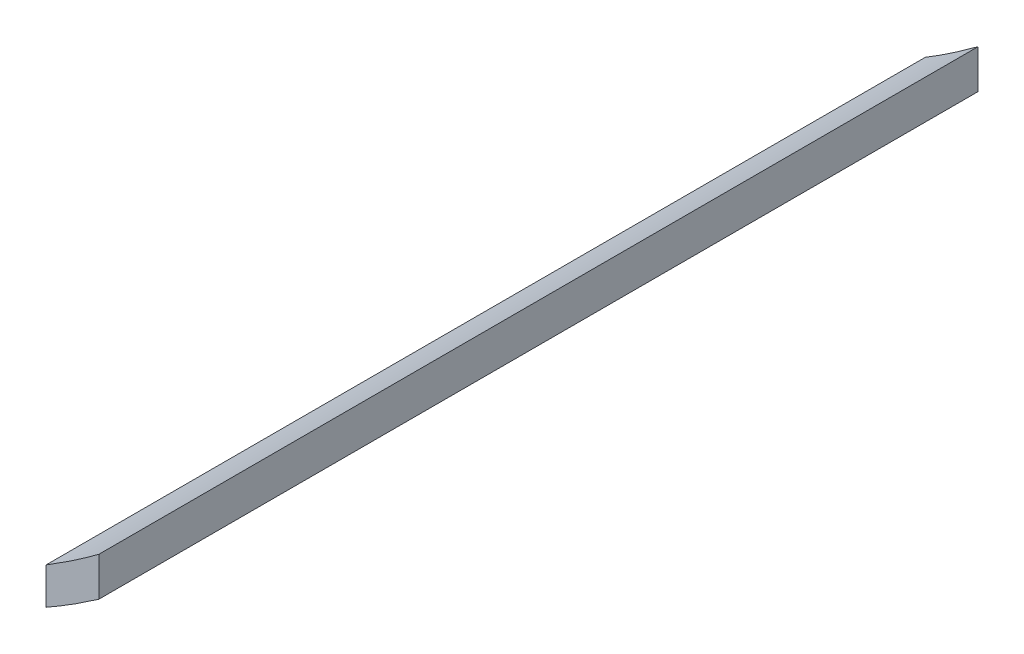
from build123d import *

# Parameters (mm, degrees)
BOSS_EXTRUDE1_DEPTH = 50


with BuildPart() as part:
    # Sketch1 → Boss-Extrude1 (new body)
    with BuildSketch(Plane.XY):
        with BuildLine():
            Line((124.702606635, -48.542565188), (124.702606635, -50.756201419))
            add(Edge.make_bspline(
                [(121.702606635, -52.650076199), (122.143324793, -52.401542151), (122.578079076, -52.142760537), (123.581396627, -51.517175339), (124.146163113, -51.14314056), (124.702606635, -50.756201419)],
                knots=[0.649205425, 0.649205425, 0.649205425, 0.649205425, 0.75, 0.75, 0.885223183, 0.885223183, 0.885223183, 0.885223183], degree=3))
            Line((121.702606635, -52.650076199), (121.702606635, -50.564547966))
            add(Edge.make_bspline(
                [(124.702606635, -48.542565188), (124.140009695, -48.957011343), (123.56913086, -49.359382085), (122.565266453, -50.027741848), (122.137178932, -50.30087247), (121.702606635, -50.564547966)],
                knots=[0.11406222, 0.11406222, 0.11406222, 0.11406222, 0.25, 0.25, 0.348787923, 0.348787923, 0.348787923, 0.348787923], degree=3))
        make_face()
    extrude(amount=BOSS_EXTRUDE1_DEPTH)


solid = part.part
